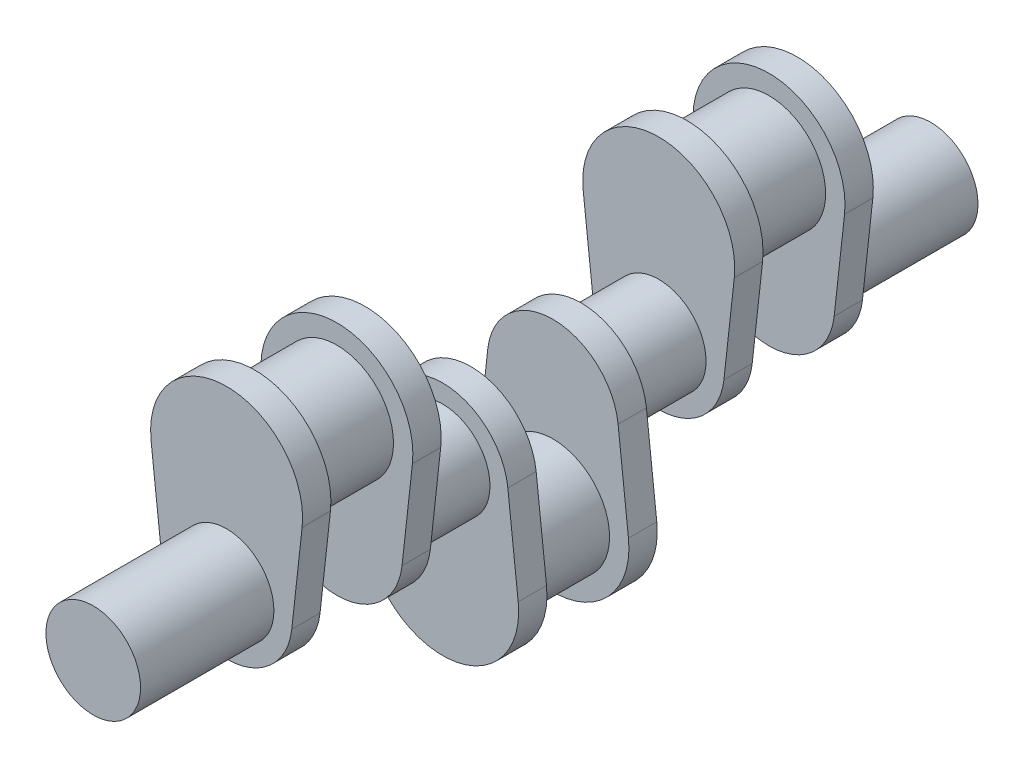
from build123d import *

# Parameters (mm, degrees)
SKETCH1_R           = 31.75
BOSS_EXTRUDE1_DEPTH = 89.5
BOSS_EXTRUDE2_DEPTH = 19
SKETCH3_R           = 38
BOSS_EXTRUDE3_DEPTH = 55
BOSS_EXTRUDE4_DEPTH = 19
SKETCH6_R           = 31.75
BOSS_EXTRUDE5_DEPTH = 52
BOSS_EXTRUDE6_DEPTH = 19
SKETCH8_R           = 38
BOSS_EXTRUDE7_DEPTH = 27.5


with BuildPart() as part:
    # Sketch1 → Boss-Extrude1 (new body)
    with BuildSketch(Plane.XY):
        Circle(SKETCH1_R)
    extrude(amount=BOSS_EXTRUDE1_DEPTH)

    # Sketch2 → Boss-Extrude2 (add)
    with BuildSketch(Plane.XY.offset(89.5)):
        with BuildLine():
            Line((-50.689176209, 57.877952756), (-43.731838298, -4.850393701))
            ThreePointArc((-43.731838298, -4.850393701), (0, -44), (43.731838298, -4.850393701))
            Line((43.731838298, -4.850393701), (50.689176209, 57.877952756))
            ThreePointArc((50.689176209, 57.877952756), (0, 114.5), (-50.689176209, 57.877952756))
        make_face()
    extrude(amount=BOSS_EXTRUDE2_DEPTH)

    # Sketch3 → Boss-Extrude3 (add)
    with BuildSketch(Plane.XY.offset(108.5)):
        with Locations((0, 63.5)):
            Circle(SKETCH3_R)
    extrude(amount=BOSS_EXTRUDE3_DEPTH)

    # Sketch5 → Boss-Extrude4 (add)
    with BuildSketch(Plane.XY.offset(163.5)):
        with BuildLine():
            Line((-50.689176209, 57.877952756), (-43.731838298, -4.850393701))
            ThreePointArc((-43.731838298, -4.850393701), (0, -44), (43.731838298, -4.850393701))
            Line((43.731838298, -4.850393701), (50.689176209, 57.877952756))
            ThreePointArc((50.689176209, 57.877952756), (0, 114.5), (-50.689176209, 57.877952756))
        make_face()
    extrude(amount=BOSS_EXTRUDE4_DEPTH)

    # Sketch6 → Boss-Extrude5 (add)
    with BuildSketch(Plane.XY.offset(182.5)):
        Circle(SKETCH6_R)
    extrude(amount=BOSS_EXTRUDE5_DEPTH)

    # Sketch7 → Boss-Extrude6 (add)
    with BuildSketch(Plane.XY.offset(234.5)):
        with BuildLine():
            Line((50.689176209, -57.877952756), (43.731838298, 4.850393701))
            ThreePointArc((43.731838298, 4.850393701), (0, 44), (-43.731838298, 4.850393701))
            Line((-43.731838298, 4.850393701), (-50.689176209, -57.877952756))
            ThreePointArc((-50.689176209, -57.877952756), (0, -114.5), (50.689176209, -57.877952756))
        make_face()
    extrude(amount=BOSS_EXTRUDE6_DEPTH)

    # Sketch8 → Boss-Extrude7 (add)
    with BuildSketch(Plane.XY.offset(253.5)):
        with Locations((0, -63.5)):
            Circle(SKETCH8_R)
    extrude(amount=BOSS_EXTRUDE7_DEPTH)

    # Mirror3: part across plane


with BuildPart() as part_1:
    add(part.part)
    add(part.part.mirror(Plane.XY.offset(281)))


solid = part_1.part
